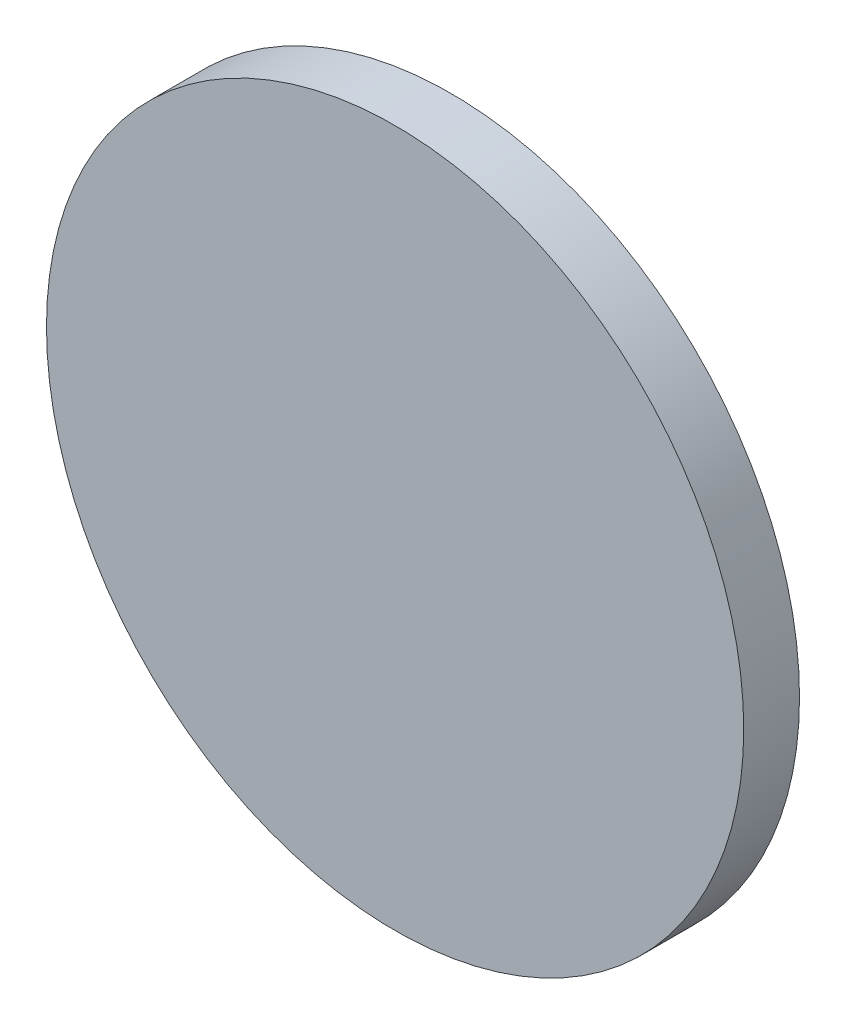
from build123d import *

# Parameters (mm, degrees)
SKETCH_1_R      = 12.5
EXTRUDE_1_DEPTH = 2


with BuildPart() as part:
    # 草图1 → 凸台-拉伸1 (new body)
    with BuildSketch(Plane.XY):
        Circle(SKETCH_1_R)
    extrude(amount=EXTRUDE_1_DEPTH)


solid = part.part
